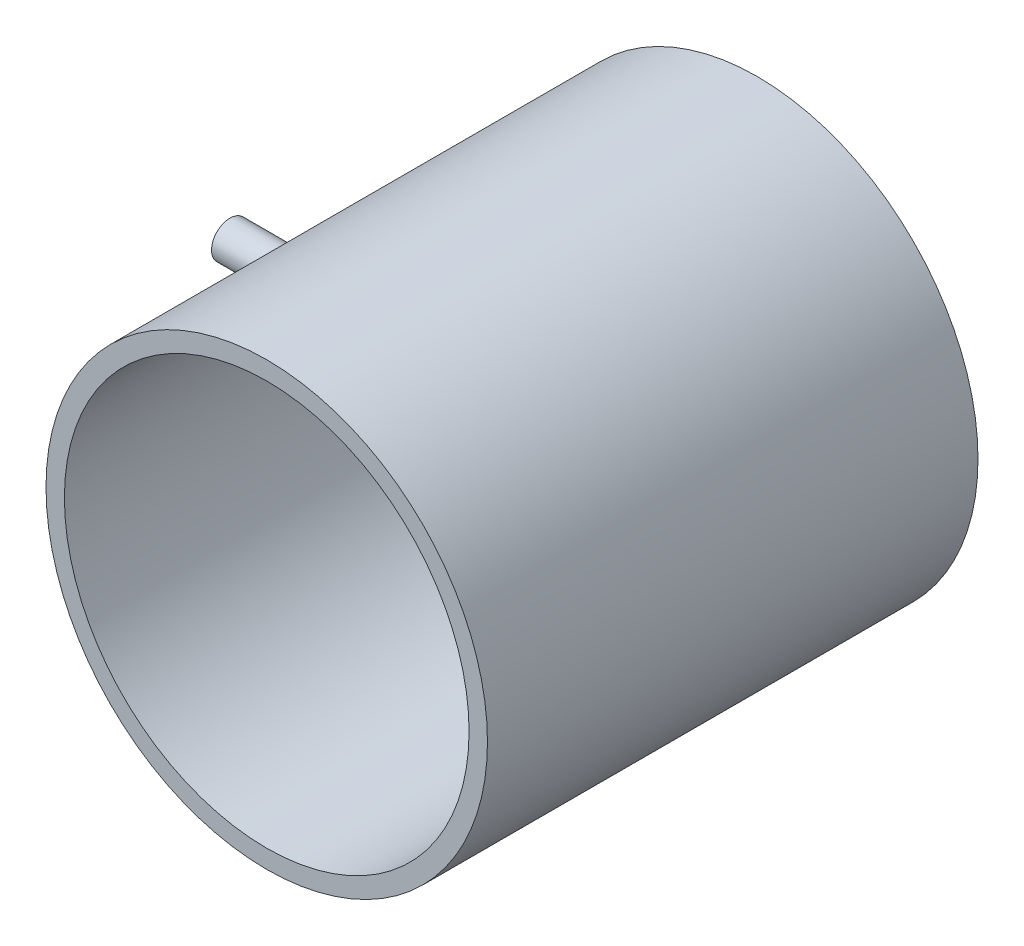
from build123d import *

# Parameters (mm, degrees)
ESQUISSE1_R        = 18
ESQUISSE1_R_2      = 16.5
BOSS_EXTRU_1_DEPTH = 40
BOSS_EXTRU_2_START = -0.062609
ESQUISSE2_R        = 1.5
BOSS_EXTRU_2_DEPTH = 10.062609


with BuildPart() as part:
    # Esquisse1 → Boss.-Extru.1 (new body)
    with BuildSketch(Plane.XY):
        with Locations((-37.141296753, 71.05304224)):
            Circle(ESQUISSE1_R)
        with Locations((-37.141296753, 71.05304224)):
            Circle(ESQUISSE1_R_2, mode=Mode.SUBTRACT)
    extrude(amount=-BOSS_EXTRU_1_DEPTH)

    # Esquisse2 → Boss.-Extru.2 (add)
    with BuildSketch(Plane.ZY.offset(55.141296753).offset(BOSS_EXTRU_2_START)):
        with Locations((-25, 71.05304224)):
            Circle(ESQUISSE2_R)
    extrude(amount=BOSS_EXTRU_2_DEPTH)


solid = part.part
